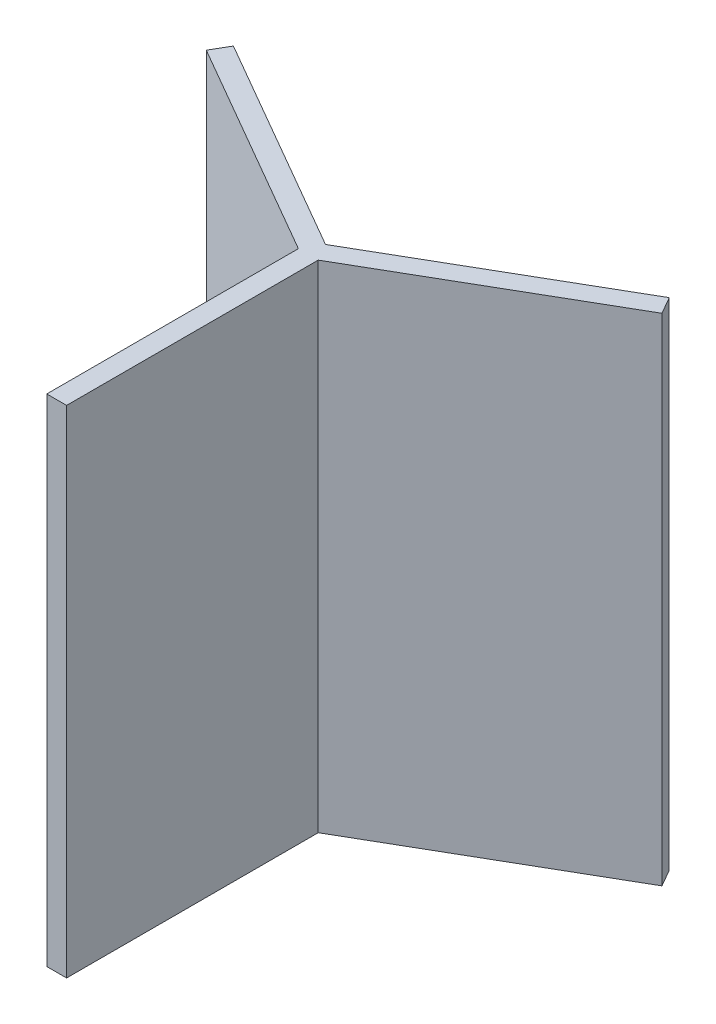
from build123d import *

# Parameters (mm, degrees)
BOSS_EXTRUDE1_DEPTH = 5000


with BuildPart() as part:
    # Sketch1 → Boss-Extrude1 (new body)
    with BuildSketch(Plane(origin=(0, 0, 0), x_dir=(1, 0, 0), z_dir=(0, 1, 0))):
        Polygon((-100, -2594.877721879), (100, -2594.877721879), (100, -57.735026919), (2297.230026861, 1210.836320561), (2197.230026861, 1384.041401318), (0, 115.470053838), (-2197.230026861, 1384.041401318), (-2297.230026861, 1210.836320561), (-100, -57.735026919), align=None)
    extrude(amount=BOSS_EXTRUDE1_DEPTH)


solid = part.part
